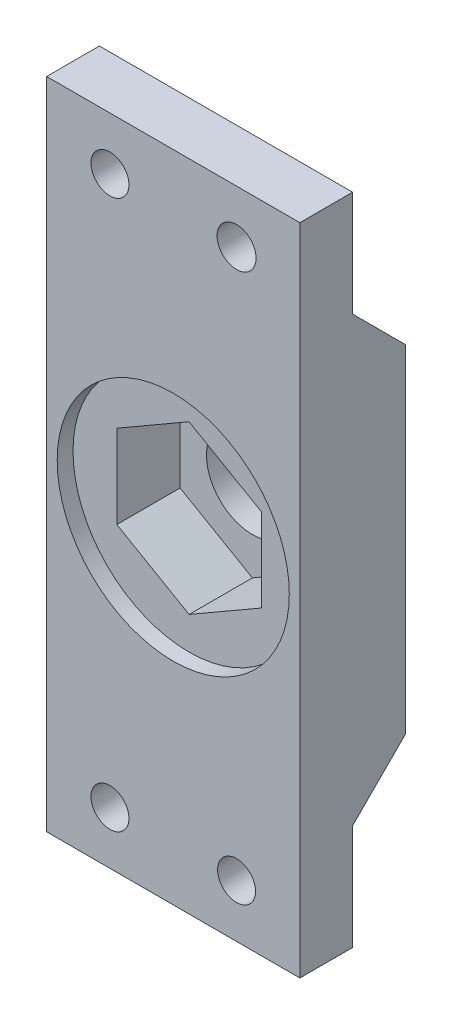
from build123d import *

# Parameters (mm, degrees)
ESBO_O1_W                = 24
ESBO_O1_H                = 62
RESSALTO_EXTRUS_O1_DEPTH = 10
ESBO_O4_R                = 11
CORTE_EXTRUS_O1_DEPTH    = 1.5
CORTE_EXTRUS_O2_DEPTH    = 6
ESBO_O9_R                = 4.35
ESBO_O9_R_2              = 1.85
ESBO_O9_R_3              = 1.8
CORTE_EXTRUS_O4_DEPTH    = 11
ESBO_O11_OUTSIDE_W       = 25.446
ESBO_O11_OUTSIDE_H       = 77.446
CORTE_EXTRUS_O7_DEPTH    = 25


with BuildPart() as part:
    # Esboço1 → Ressalto-extrusão1 (new body)
    with BuildSketch(Plane.XY):
        Rectangle(ESBO_O1_W, ESBO_O1_H)
    extrude(amount=RESSALTO_EXTRUS_O1_DEPTH)

    # Esboço4 → Corte-extrusão1 (cut)
    with BuildSketch(Plane(origin=(0, 0, 10), x_dir=(-1, 0, 0), z_dir=(0, 0, -1))):
        Circle(ESBO_O4_R)
    extrude(amount=CORTE_EXTRUS_O1_DEPTH, mode=Mode.SUBTRACT)

    # Esboço6 → Corte-extrusão2 (cut)
    with BuildSketch(Plane.XY.offset(8.5)):
        Polygon((0, -7.909698688), (6.85, -3.954849344), (6.85, 3.954849344), (0, 7.909698688), (-6.85, 3.954849344), (-6.85, -3.954849344), align=None)
    extrude(amount=-CORTE_EXTRUS_O2_DEPTH, mode=Mode.SUBTRACT)

    # Esboço9 → Corte-extrusão4 (cut, through all)
    with BuildSketch(Plane.XY.offset(10)):
        Circle(ESBO_O9_R)
        with Locations((6, 26)):
            Circle(ESBO_O9_R_2)
        with Locations((-6, 26)):
            Circle(ESBO_O9_R_3)
        with Locations((-6, -26)):
            Circle(ESBO_O9_R_3)
        with Locations((6, -26)):
            Circle(ESBO_O9_R_3)
    extrude(amount=-CORTE_EXTRUS_O4_DEPTH, mode=Mode.SUBTRACT)

    # Esboço11 outside → Corte-extrusão7 (cut, through all)
    with BuildSketch(Plane.ZY.offset(12)):
        with Locations((5, 0)):
            Rectangle(ESBO_O11_OUTSIDE_W, ESBO_O11_OUTSIDE_H)
        Polygon((5.004562024, -21), (5, -31), (10, -31), (10, 31), (5, 31), (5.004562024, 21), (0, 15.995437976), (0, -15.995437976), align=None, mode=Mode.SUBTRACT)
    extrude(amount=-CORTE_EXTRUS_O7_DEPTH, mode=Mode.SUBTRACT)


solid = part.part
